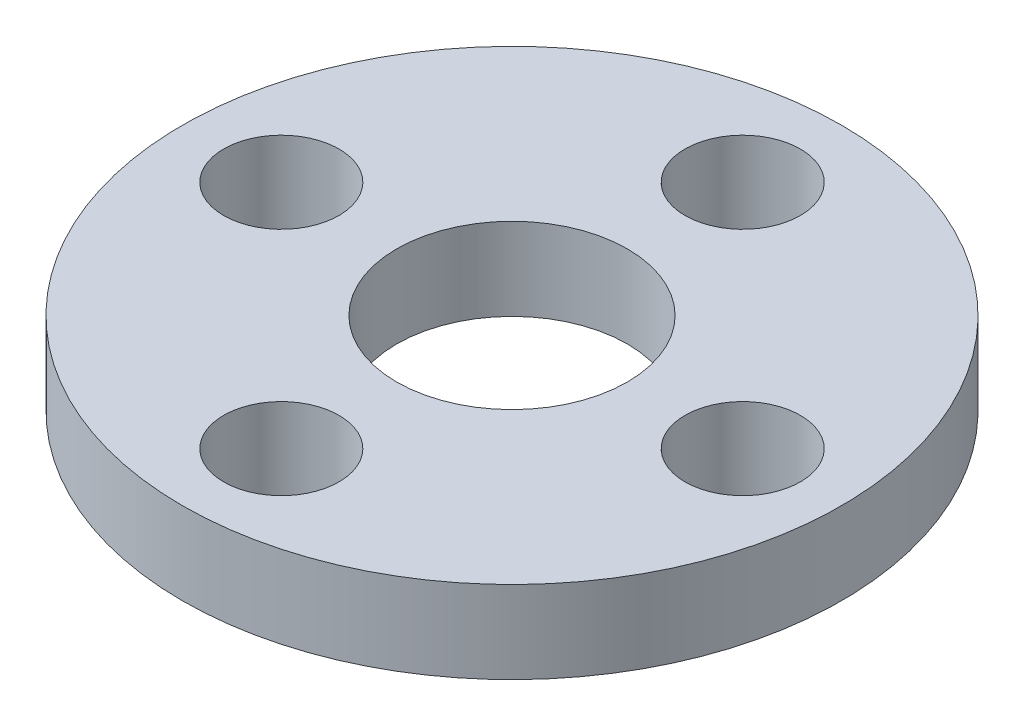
from build123d import *

# Parameters (mm, degrees)
SKETCH_1_R          = 10
SKETCH_1_R_2        = 1.75
EXTRUDE_1_DEPTH     = 2.5
SKETCH_2_R          = 3.5
CUT_EXTRUDE_1_DEPTH = 3.5


with BuildPart() as part:
    # Эскиз1 → Бобышка-Вытянуть1 (new body)
    with BuildSketch(Plane(origin=(0, 0, 0), x_dir=(1, 0, 0), z_dir=(0, 1, 0))):
        Circle(SKETCH_1_R)
        with Locations((-7, 0)):
            Circle(SKETCH_1_R_2, mode=Mode.SUBTRACT)
        with Locations((0, 7)):
            Circle(SKETCH_1_R_2, mode=Mode.SUBTRACT)
        with Locations((7, 0)):
            Circle(SKETCH_1_R_2, mode=Mode.SUBTRACT)
        with Locations((0, -7)):
            Circle(SKETCH_1_R_2, mode=Mode.SUBTRACT)
    extrude(amount=EXTRUDE_1_DEPTH)

    # Эскиз2 → Вырез-Вытянуть1 (cut, through all)
    with BuildSketch(Plane(origin=(0, 2.5, 0), x_dir=(1, 0, 0), z_dir=(0, 1, 0))):
        Circle(SKETCH_2_R)
    extrude(amount=-CUT_EXTRUDE_1_DEPTH, mode=Mode.SUBTRACT)


solid = part.part
